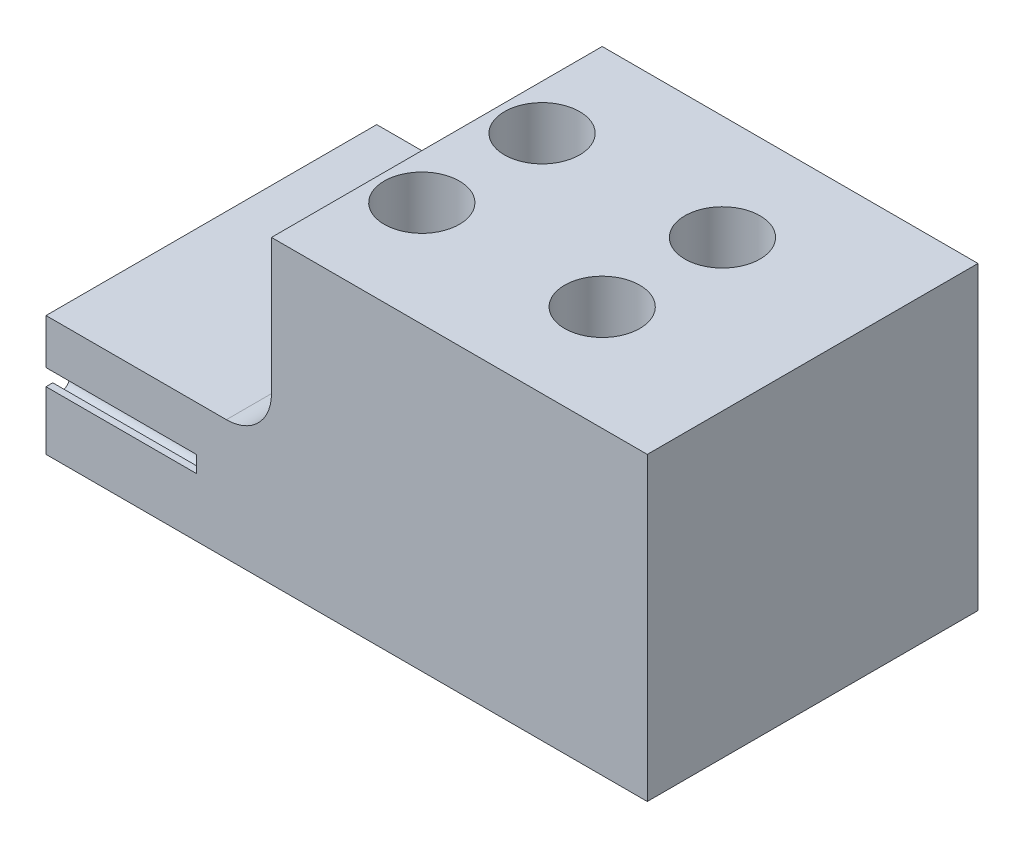
from build123d import *

# Parameters (mm, degrees)
SKETCH_1_W                   = 20
SKETCH_1_H                   = 30
EXTRUDE_1_DEPTH              = 30
CUT_EXTRUDE_1_DEPTH          = 10
SKETCH_15_W                  = 20
SKETCH_15_H                  = 30
CUT_EXTRUDE_6_DEPTH          = 10
SKETCH_16_W                  = 30
SKETCH_16_H                  = 20
EXTRUDE_5_DEPTH              = 20
HOLE_WIZARD_M2_2_D           = 2.4
HOLE_WIZARD_M2_2_CSINK_D     = 2.45
HOLE_WIZARD_M2_2_CSINK_ANGLE = 90
SKETCH_20_R                  = 2.5
CUT_EXTRUDE_7_DEPTH          = 12
SKETCH_21_W                  = 15
SKETCH_21_H                  = 12
CUT_EXTRUDE_8_DEPTH          = 31
SKETCH_22_W                  = 40
SKETCH_22_H                  = 4
CUT_EXTRUDE_9_DEPTH          = 21
FILLET_1_R                   = 3


with BuildPart() as part:
    # 草图1 → 凸台-拉伸1 (new body)
    with BuildSketch(Plane.XY):
        with Locations((10, 15)):
            Rectangle(SKETCH_1_W, SKETCH_1_H)
    extrude(amount=EXTRUDE_1_DEPTH)

    # 草图3 → 切除-拉伸1 (cut)
    with BuildSketch(Plane.ZY):
        with BuildLine():
            Line((11.550000034, 3.65), (11.550000034, 3.899807334))
            Line((11.550000034, 3.899807334), (12.450000034, 3.899807334))
            Line((12.450000034, 3.899807334), (12.450000034, 3.649807334))
            ThreePointArc((12.450000034, 3.649807334), (13, 3.1), (13.549999966, 3.649807334))
            Line((13.549999966, 3.649807334), (13.549999966, 3.899807334))
            Line((13.549999966, 3.899807334), (14.449999966, 3.899807334))
            Line((14.449999966, 3.899807334), (14.449999966, 3.65))
            ThreePointArc((14.449999966, 3.65), (15, 3.099999966), (15.550000034, 3.65))
            Line((15.550000034, 3.65), (15.550000034, 3.899807334))
            Line((15.550000034, 3.899807334), (16.450000034, 3.899807334))
            Line((16.450000034, 3.899807334), (16.450000034, 3.649807334))
            ThreePointArc((16.450000034, 3.649807334), (17, 3.1), (17.549999966, 3.649807334))
            Line((17.549999966, 3.649807334), (17.549999966, 3.899807334))
            Line((17.549999966, 3.899807334), (18.449999966, 3.899807334))
            Line((18.449999966, 3.899807334), (18.449999966, 3.65))
            ThreePointArc((18.449999966, 3.65), (19, 3.099999966), (19.550000034, 3.65))
            Line((19.550000034, 3.65), (19.550000034, 3.899807334))
            Line((19.550000034, 3.899807334), (20.450000034, 3.899807334))
            Line((20.450000034, 3.899807334), (20.450000034, 3.649807334))
            ThreePointArc((20.450000034, 3.649807334), (21, 3.1), (21.549999966, 3.649807334))
            Line((21.549999966, 3.649807334), (21.549999966, 3.899807334))
            Line((21.549999966, 3.899807334), (22.449999966, 3.899807334))
            Line((22.449999966, 3.899807334), (22.449999966, 3.65))
            ThreePointArc((22.449999966, 3.65), (23, 3.099999966), (23.550000034, 3.65))
            Line((23.550000034, 3.65), (23.550000034, 3.899807334))
            Line((23.550000034, 3.899807334), (24.450000034, 3.899807334))
            Line((24.450000034, 3.899807334), (24.450000034, 3.649807334))
            ThreePointArc((24.450000034, 3.649807334), (25, 3.1), (25.549999966, 3.649807334))
            Line((25.549999966, 3.649807334), (25.549999966, 3.899807334))
            Line((25.549999966, 3.899807334), (26.449999966, 3.899807334))
            Line((26.449999966, 3.899807334), (26.449999966, 3.65))
            ThreePointArc((26.449999966, 3.65), (27, 3.099999966), (27.550000034, 3.65))
            Line((27.550000034, 3.65), (27.550000034, 3.899807334))
            Line((27.550000034, 3.899807334), (28.450000034, 3.899807334))
            Line((28.450000034, 3.899807334), (28.450000034, 3.649807334))
            ThreePointArc((28.450000034, 3.649807334), (29, 3.1), (29.549999966, 3.649807334))
            Line((29.549999966, 3.649807334), (29.549999966, 3.899807334))
            Line((29.549999966, 3.899807334), (30.449999966, 3.899807334))
            Line((30.449999966, 3.899807334), (30.449999966, 3.65))
            ThreePointArc((30.449999966, 3.65), (30.61109127, 3.26109127), (31, 3.1))
            Line((31, 3.1), (31, 5))
            Line((31, 5), (15, 5))
            Line((15, 5), (-1, 5))
            Line((-1, 5), (-1, 3.1))
            ThreePointArc((-1, 3.1), (-0.61109127, 3.26109127), (-0.449999966, 3.65))
            Line((-0.449999966, 3.65), (-0.449999966, 3.899807334))
            Line((-0.449999966, 3.899807334), (0.450000034, 3.899807334))
            Line((0.450000034, 3.899807334), (0.450000034, 3.649807334))
            ThreePointArc((0.450000034, 3.649807334), (1, 3.1), (1.549999966, 3.649807334))
            Line((1.549999966, 3.649807334), (1.549999966, 3.899807334))
            Line((1.549999966, 3.899807334), (2.449999966, 3.899807334))
            Line((2.449999966, 3.899807334), (2.449999966, 3.65))
            ThreePointArc((2.449999966, 3.65), (3, 3.099999966), (3.550000034, 3.65))
            Line((3.550000034, 3.65), (3.550000034, 3.899807334))
            Line((3.550000034, 3.899807334), (4.450000034, 3.899807334))
            Line((4.450000034, 3.899807334), (4.450000034, 3.649807334))
            ThreePointArc((4.450000034, 3.649807334), (5, 3.1), (5.549999966, 3.649807334))
            Line((5.549999966, 3.649807334), (5.549999966, 3.899807334))
            Line((5.549999966, 3.899807334), (6.449999966, 3.899807334))
            Line((6.449999966, 3.899807334), (6.449999966, 3.65))
            ThreePointArc((6.449999966, 3.65), (7, 3.099999966), (7.550000034, 3.65))
            Line((7.550000034, 3.65), (7.550000034, 3.899807334))
            Line((7.550000034, 3.899807334), (8.450000034, 3.899807334))
            Line((8.450000034, 3.899807334), (8.450000034, 3.649807334))
            ThreePointArc((8.450000034, 3.649807334), (9, 3.1), (9.549999966, 3.649807334))
            Line((9.549999966, 3.649807334), (9.549999966, 3.899807334))
            Line((9.549999966, 3.899807334), (10.449999966, 3.899807334))
            Line((10.449999966, 3.899807334), (10.449999966, 3.65))
            ThreePointArc((10.449999966, 3.65), (11, 3.099999966), (11.550000034, 3.65))
        make_face()
    extrude(amount=-CUT_EXTRUDE_1_DEPTH, mode=Mode.SUBTRACT)

    # 草图15 → 切除-拉伸6 (cut)
    with BuildSketch(Plane(origin=(0, 30, 0), x_dir=(1, 0, 0), z_dir=(0, 1, 0))):
        with Locations((10, -15)):
            Rectangle(SKETCH_15_W, SKETCH_15_H)
    extrude(amount=-CUT_EXTRUDE_6_DEPTH, mode=Mode.SUBTRACT)

    # 草图16 → 凸台-拉伸5 (add)
    with BuildSketch(Plane(origin=(20, 0, 0), x_dir=(0, 0, -1), z_dir=(1, 0, 0))):
        with Locations((-15, 10)):
            Rectangle(SKETCH_16_W, SKETCH_16_H)
    extrude(amount=EXTRUDE_5_DEPTH)

    # M2 间隙孔2 (through all)
    with Locations(Plane(origin=(0, 20, 0), x_dir=(1, 0, 0), z_dir=(0, 1, 0))):
        with Locations((18, -19), (18, -11), (30, -11), (30, -19)):
            CounterSinkHole(HOLE_WIZARD_M2_2_D / 2, HOLE_WIZARD_M2_2_CSINK_D / 2, counter_sink_angle=HOLE_WIZARD_M2_2_CSINK_ANGLE)

    # 草图20 → 切除-拉伸7 (cut)
    with BuildSketch(Plane(origin=(0, 20, 0), x_dir=(1, 0, 0), z_dir=(0, 1, 0))):
        with Locations((18, -11)):
            Circle(SKETCH_20_R)
        with Locations((30, -11)):
            Circle(SKETCH_20_R)
        with Locations((30, -19)):
            Circle(SKETCH_20_R)
        with Locations((18, -19)):
            Circle(SKETCH_20_R)
    extrude(amount=-CUT_EXTRUDE_7_DEPTH, mode=Mode.SUBTRACT)

    # 草图21 → 切除-拉伸8 (cut, through all)
    with BuildSketch(Plane(origin=(0, 0, 0), x_dir=(-1, 0, 0), z_dir=(0, 0, -1))):
        with Locations((-7.5, 14)):
            Rectangle(SKETCH_21_W, SKETCH_21_H)
    extrude(amount=-CUT_EXTRUDE_8_DEPTH, mode=Mode.SUBTRACT)

    # 草图22 → 切除-拉伸9 (cut, through all)
    with BuildSketch(Plane.XZ):
        with Locations((20, 28)):
            Rectangle(SKETCH_22_W, SKETCH_22_H)
        with Locations((20, 2)):
            Rectangle(SKETCH_22_W, SKETCH_22_H)
    extrude(amount=-CUT_EXTRUDE_9_DEPTH, mode=Mode.SUBTRACT)

    # 圆角1
    fillet_1_edges = [part.edges().sort_by_distance(p)[0] for p in [
        (15, 8, 15),
    ]]
    fillet(fillet_1_edges, radius=FILLET_1_R)


solid = part.part
